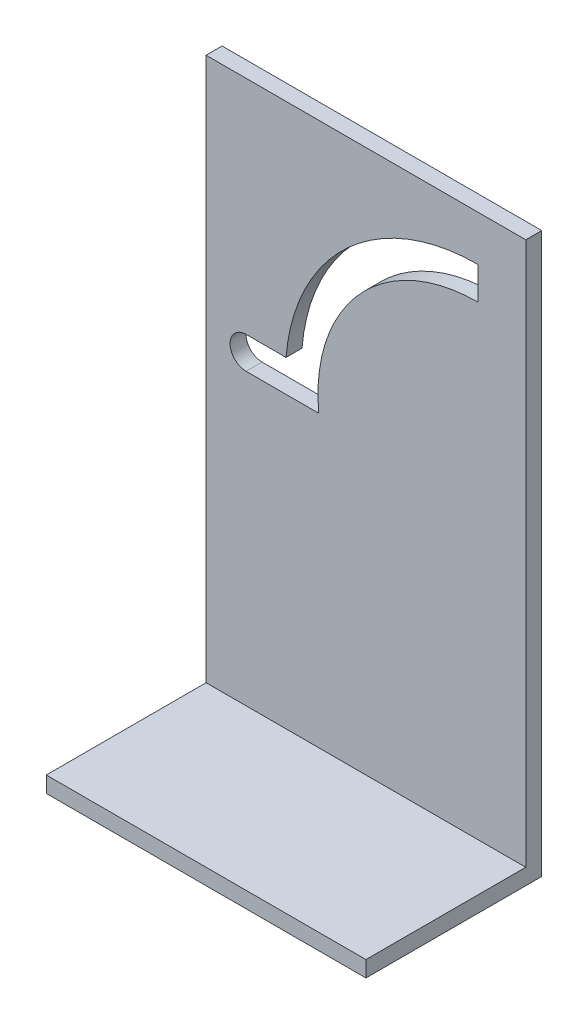
from build123d import *

# Parameters (mm, degrees)
SKETCH_1_W      = 40
SKETCH_1_H      = 70
EXTRUDE_1_DEPTH = 2
SKETCH_2_W      = 40
SKETCH_2_H      = 2
EXTRUDE_2_DEPTH = 20


with BuildPart() as part:
    # 草图1 → 凸台-拉伸1 (new body)
    with BuildSketch(Plane.XY):
        with Locations((-10.271445819, -4.719420773)):
            Rectangle(SKETCH_1_W, SKETCH_1_H)
        with BuildLine():
            Line((-25.271445819, -1.469420773), (-20.271445819, -1.469420773))
            Line((-20.271445819, -1.469420773), (-16.171194561, -1.469420773))
            ThreePointArc((-16.171194561, -1.469420773), (-11.103842793, 13.946987092), (3.728554181, 20.530579227))
            Line((3.728554181, 20.530579227), (3.728554181, 24.613768385))
            ThreePointArc((3.728554181, 24.613768385), (-12.578401723, 18.252971536), (-20.271445819, 2.530579227))
            Line((-20.271445819, 2.530579227), (-25.271445819, 2.530579227))
            ThreePointArc((-25.271445819, 2.530579227), (-27.271445819, 0.530579227), (-25.271445819, -1.469420773))
        make_face(mode=Mode.SUBTRACT)
    extrude(amount=EXTRUDE_1_DEPTH)

    # 草图2 → 凸台-拉伸2 (add)
    with BuildSketch(Plane.XY.offset(2)):
        with Locations((-10.271445819, -38.719420773)):
            Rectangle(SKETCH_2_W, SKETCH_2_H)
    extrude(amount=EXTRUDE_2_DEPTH)


solid = part.part
